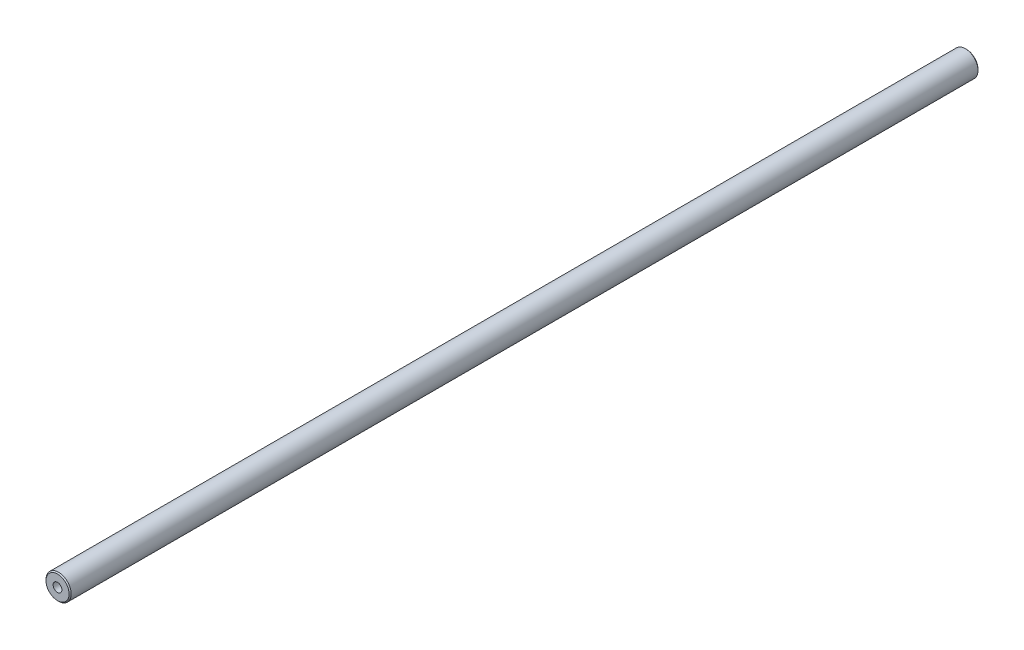
from build123d import *

# Parameters (mm, degrees)
SKETCH1_R                           = 6
BOSS_EXTRUDE1_DEPTH                 = 433.48108
CHAMFER1_SIZE                       = 0.5
M5X0_8_TAPPED_HOLE1_D               = 4.2
M5X0_8_TAPPED_HOLE1_DEPTH           = 16.4
M5X0_8_TAPPED_HOLE1_TIP             = 1.2618073
M5X0_8_TAPPED_HOLE1_ON_FACE_2_D     = 4.2
M5X0_8_TAPPED_HOLE1_ON_FACE_2_DEPTH = 16.4
M5X0_8_TAPPED_HOLE1_ON_FACE_2_TIP   = 1.2618073


with BuildPart() as part:
    # Sketch1 → Boss-Extrude1 (new body)
    with BuildSketch(Plane.XY):
        Circle(SKETCH1_R)
    extrude(amount=BOSS_EXTRUDE1_DEPTH)

    # Chamfer1
    chamfer1_edges = [part.edges().sort_by_distance(p)[0] for p in [
        (-6, 0, 0),
        (-6, 0, 433.48108),
    ]]
    chamfer(chamfer1_edges, length=CHAMFER1_SIZE)

    # M5x0.8 Tapped Hole1
    with Locations(Plane(origin=(0, 0, 433.48108), x_dir=(0, 1, 0), z_dir=(0, 0, 1))):
        with Locations((0, 0)):
            Hole(M5X0_8_TAPPED_HOLE1_D / 2, depth=M5X0_8_TAPPED_HOLE1_DEPTH)
            with Locations((0, 0, -(M5X0_8_TAPPED_HOLE1_DEPTH + M5X0_8_TAPPED_HOLE1_TIP / 2))):  # 118° drill point
                Cone(0, M5X0_8_TAPPED_HOLE1_D / 2, M5X0_8_TAPPED_HOLE1_TIP, mode=Mode.SUBTRACT)

    # M5x0.8 Tapped Hole1 on face 2
    with Locations(Plane(origin=(0, 0, 0), x_dir=(-1, 0, 0), z_dir=(0, 0, -1))):
        with Locations((0, 0)):
            Hole(M5X0_8_TAPPED_HOLE1_ON_FACE_2_D / 2, depth=M5X0_8_TAPPED_HOLE1_ON_FACE_2_DEPTH)
            with Locations((0, 0, -(M5X0_8_TAPPED_HOLE1_ON_FACE_2_DEPTH + M5X0_8_TAPPED_HOLE1_ON_FACE_2_TIP / 2))):  # 118° drill point
                Cone(0, M5X0_8_TAPPED_HOLE1_ON_FACE_2_D / 2, M5X0_8_TAPPED_HOLE1_ON_FACE_2_TIP, mode=Mode.SUBTRACT)


solid = part.part
